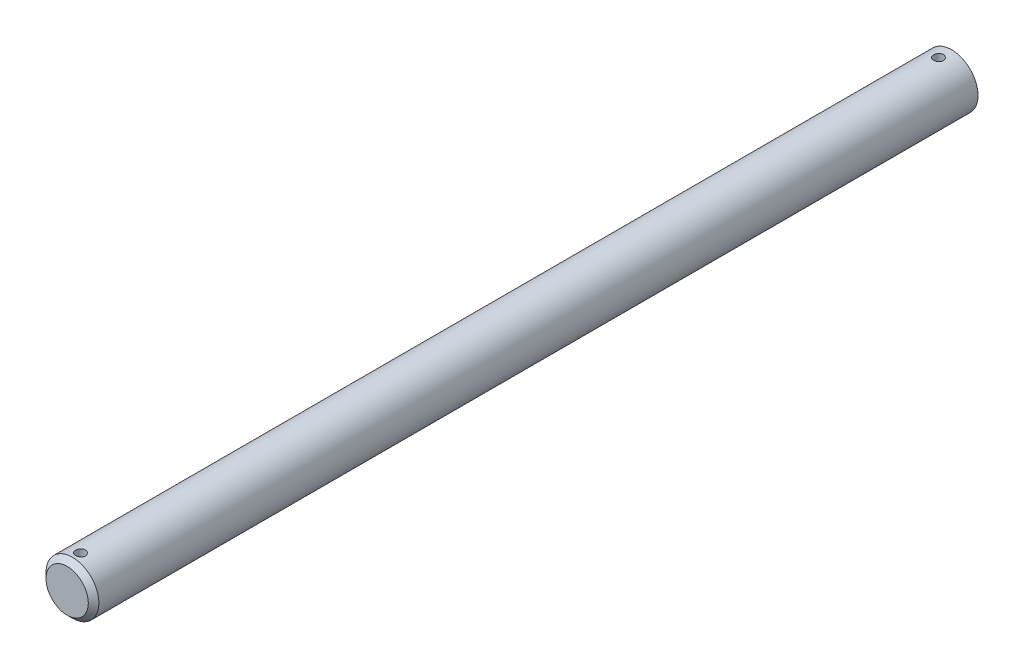
from build123d import *

# Parameters (mm, degrees)
SKETCH3_R               = 3.175
BOSS_EXTRUDE1_DEPTH     = 304.8
CHAMFER1_SIZE           = 0.635
CUT_EXTRUDE1_START      = -106.219625
SKETCH4_R               = 3.175
CUT_EXTRUDE1_DEPTH      = 504.380375
SKETCH5_R               = 0.5953125
CUT_EXTRUDE2_DEPTH      = 4.175
CUT_EXTRUDE2_DEPTH_BACK = 4.175


with BuildPart() as part:
    # Sketch3 → Boss-Extrude1 (new body, symmetric)
    with BuildSketch(Plane.XY):
        Circle(SKETCH3_R)
    extrude(amount=BOSS_EXTRUDE1_DEPTH, both=True)

    # Chamfer1
    chamfer1_edges = [part.edges().sort_by_distance(p)[0] for p in [
        (-3.175, 0, -304.8),
        (-3.175, 0, 304.8),
    ]]
    chamfer(chamfer1_edges, length=CHAMFER1_SIZE)

    # Sketch4 → Cut-Extrude1 (cut, through all)
    with BuildSketch(Plane.XY.offset(304.8).offset(CUT_EXTRUDE1_START)):
        Circle(SKETCH4_R)
    extrude(amount=-CUT_EXTRUDE1_DEPTH, mode=Mode.SUBTRACT)

    # Sketch5 → Cut-Extrude2 (cut, two sides)
    with BuildSketch(Plane(origin=(0, 0, 0), x_dir=(1, 0, 0), z_dir=(0, 1, 0))) as cut_extrude2_sk:
        with Locations((0, -200.167875)):
            Circle(SKETCH5_R)
        with Locations((0, -303.2125)):
            Circle(SKETCH5_R)
    extrude(amount=CUT_EXTRUDE2_DEPTH, mode=Mode.SUBTRACT)
    extrude(cut_extrude2_sk.sketch, amount=-CUT_EXTRUDE2_DEPTH_BACK, mode=Mode.SUBTRACT)


solid = part.part
